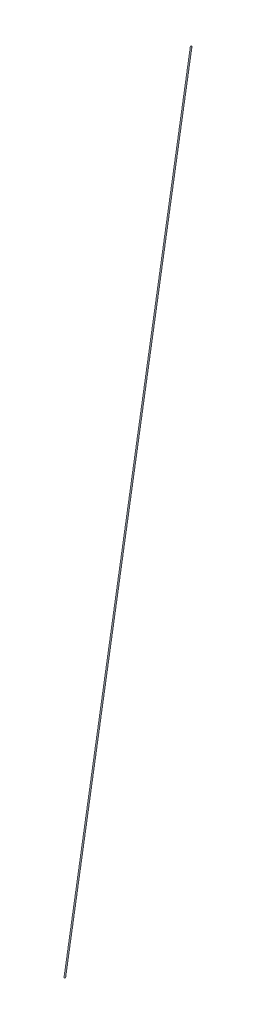
from build123d import *

# Parameters (mm, degrees)
SKETCH_6_R = 1


with BuildPart() as part:
    # 扫描1: sweep along a path in 草图5
    with BuildLine(Plane(origin=(0, 0, 0), x_dir=(0, 0, -1), z_dir=(1, 0, 0))) as sweep_1_path:
        Line((0, 0), (217.5, 1279.38))
    # 草图6 → 扫描1 (sweep)
    with BuildSketch(Plane(origin=(0, 1279.38, -217.5), x_dir=(1, 0, 0), z_dir=(0, 0.985855159, -0.167599538))):
        Circle(SKETCH_6_R)
    sweep(path=sweep_1_path.line)


solid = part.part
